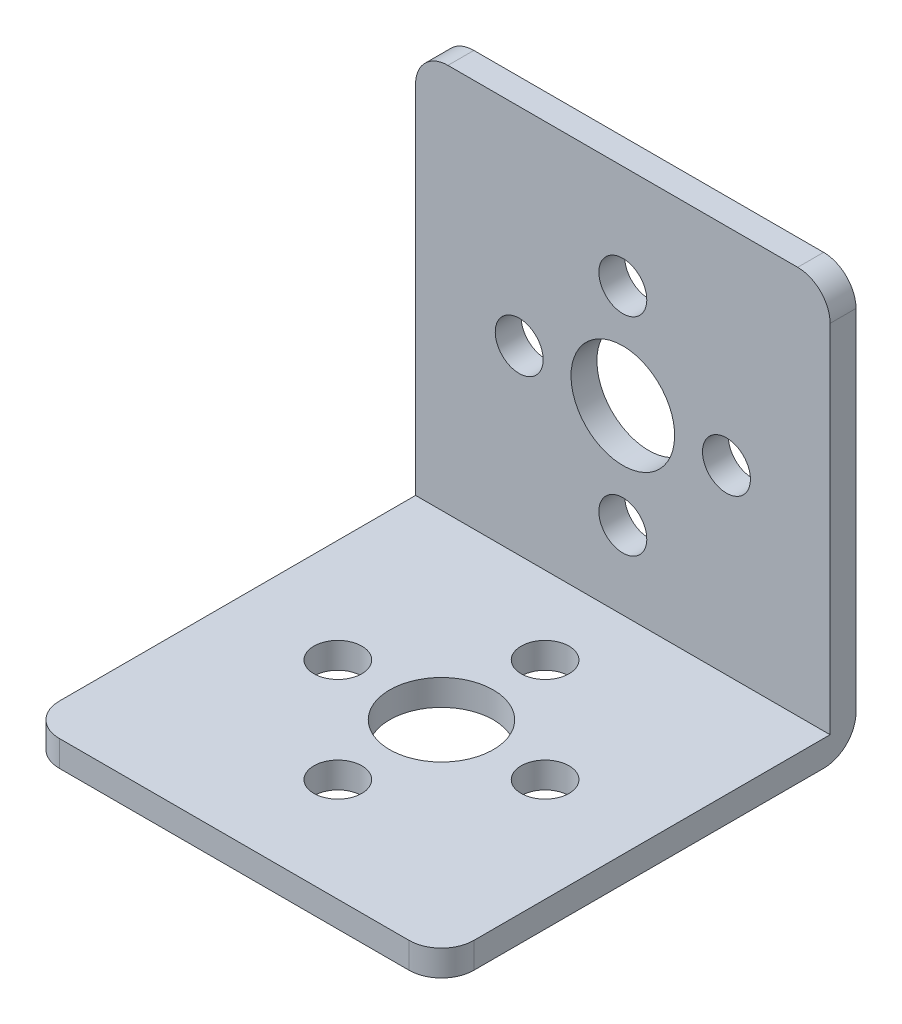
from build123d import *

# Parameters (mm, degrees)
SKETCH1_W           = 32
SKETCH1_H           = 32
BOSS_EXTRUDE1_DEPTH = 16
SKETCH2_W           = 30
SKETCH2_H           = 30
CUT_EXTRUDE1_DEPTH  = 32
SKETCH3_R           = 4
SKETCH3_R_2         = 1.85
CUT_EXTRUDE2_DEPTH  = 33
SKETCH4_R           = 4
SKETCH4_R_2         = 1.85
CUT_EXTRUDE3_DEPTH  = 33
FILLET1_R           = 2.5


with BuildPart() as part:
    # Sketch1 → Boss-Extrude1 (new body, symmetric)
    with BuildSketch(Plane(origin=(0, 0, 0), x_dir=(0, 0, -1), z_dir=(1, 0, 0))):
        Rectangle(SKETCH1_W, SKETCH1_H)
    extrude(amount=BOSS_EXTRUDE1_DEPTH, both=True)

    # Sketch2 → Cut-Extrude1 (cut)
    with BuildSketch(Plane(origin=(16, 0, 0), x_dir=(0, 0, -1), z_dir=(1, 0, 0))):
        with Locations((-1, 1)):
            Rectangle(SKETCH2_W, SKETCH2_H)
    extrude(amount=-CUT_EXTRUDE1_DEPTH, mode=Mode.SUBTRACT)

    # Sketch3 → Cut-Extrude2 (cut, through all)
    with BuildSketch(Plane(origin=(0, 0, -16), x_dir=(-1, 0, 0), z_dir=(0, 0, -1))):
        Circle(SKETCH3_R)
        with Locations((8, 0)):
            Circle(SKETCH3_R_2)
        with Locations((-8, 0)):
            Circle(SKETCH3_R_2)
        with Locations((0, 8)):
            Circle(SKETCH3_R_2)
        with Locations((0, -8)):
            Circle(SKETCH3_R_2)
    extrude(amount=-CUT_EXTRUDE2_DEPTH, mode=Mode.SUBTRACT)

    # Sketch4 → Cut-Extrude3 (cut, through all)
    with BuildSketch(Plane.XZ.offset(16)):
        Circle(SKETCH4_R)
        with Locations((8, 0)):
            Circle(SKETCH4_R_2)
        with Locations((-8, 0)):
            Circle(SKETCH4_R_2)
        with Locations((0, 8)):
            Circle(SKETCH4_R_2)
        with Locations((0, -8)):
            Circle(SKETCH4_R_2)
    extrude(amount=-CUT_EXTRUDE3_DEPTH, mode=Mode.SUBTRACT)

    # Fillet1
    fillet1_edges = [part.edges().sort_by_distance(p)[0] for p in [
        (-16, -15, 16),
        (16, -15, 16),
        (-16, 16, -15),
        (16, 16, -15),
        (0, -16, -16),
    ]]
    fillet(fillet1_edges, radius=FILLET1_R)


solid = part.part
